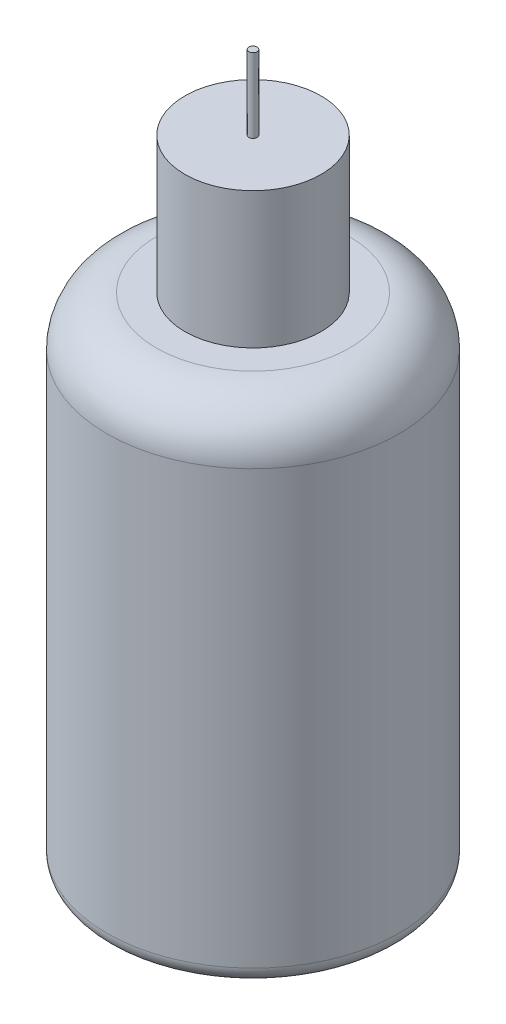
from build123d import *

# Parameters (mm, degrees)
CROQUIS1_R              = 17.7
SALIENTE_EXTRUIR1_DEPTH = 60.4
REDONDEO1_R             = 6
REDONDEO2_R             = 2
CROQUIS2_R              = 8.25
SALIENTE_EXTRUIR2_DEPTH = 16.5
CROQUIS3_R              = 0.5
SALIENTE_EXTRUIR3_DEPTH = 9


with BuildPart() as part:
    # Croquis1 → Saliente-Extruir1 (new body)
    with BuildSketch(Plane(origin=(0, 0, 0), x_dir=(1, 0, 0), z_dir=(0, 1, 0))):
        Circle(CROQUIS1_R)
    extrude(amount=SALIENTE_EXTRUIR1_DEPTH)

    # Redondeo1
    redondeo1_edges = [part.edges().sort_by_distance(p)[0] for p in [
        (-17.7, 60.4, 0),
    ]]
    fillet(redondeo1_edges, radius=REDONDEO1_R)

    # Redondeo2
    redondeo2_edges = [part.edges().sort_by_distance(p)[0] for p in [
        (-17.7, 0, 0),
    ]]
    fillet(redondeo2_edges, radius=REDONDEO2_R)

    # Croquis2 → Saliente-Extruir2 (add)
    with BuildSketch(Plane(origin=(0, 60.4, 0), x_dir=(1, 0, 0), z_dir=(0, 1, 0))):
        Circle(CROQUIS2_R)
    extrude(amount=SALIENTE_EXTRUIR2_DEPTH)

    # Croquis3 → Saliente-Extruir3 (add)
    with BuildSketch(Plane(origin=(0, 76.9, 0), x_dir=(1, 0, 0), z_dir=(0, 1, 0))):
        Circle(CROQUIS3_R)
    extrude(amount=SALIENTE_EXTRUIR3_DEPTH)


solid = part.part
